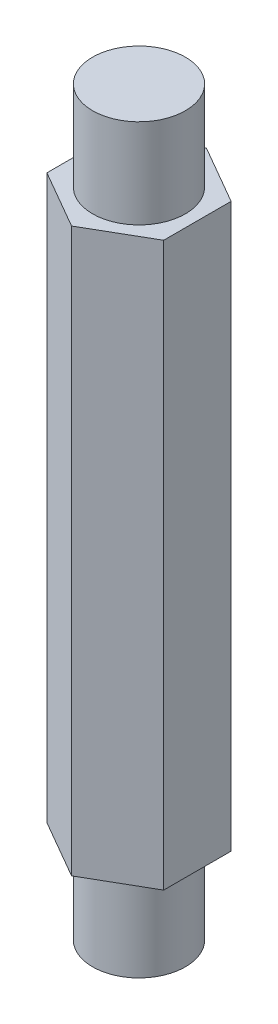
from build123d import *

# Parameters (mm, degrees)
SKETCH1_R           = 1.65
BOSS_EXTRUDE1_DEPTH = 20
SKETCH2_R           = 1.65
BOSS_EXTRUDE2_DEPTH = 3.175
SKETCH3_R           = 1.65
BOSS_EXTRUDE3_DEPTH = 3.175


with BuildPart() as part:
    # Sketch1 → Boss-Extrude1 (new body)
    with BuildSketch(Plane(origin=(0, 0, 0), x_dir=(1, 0, 0), z_dir=(0, 1, 0))):
        Polygon((0, -2.396003617), (2.075, -1.198001809), (2.075, 1.198001809), (0, 2.396003617), (-2.075, 1.198001809), (-2.075, -1.198001809), align=None)
        Circle(SKETCH1_R, mode=Mode.SUBTRACT)
    extrude(amount=BOSS_EXTRUDE1_DEPTH)


with BuildPart() as body_2:
    # Sketch2 → Boss-Extrude2 (new body)
    with BuildSketch(Plane.XZ):
        Circle(SKETCH2_R)
    extrude(amount=BOSS_EXTRUDE2_DEPTH)


with BuildPart() as body_3:
    # Sketch3 → Boss-Extrude3 (new body)
    with BuildSketch(Plane(origin=(0, 20, 0), x_dir=(1, 0, 0), z_dir=(0, 1, 0))):
        Circle(SKETCH3_R)
    extrude(amount=BOSS_EXTRUDE3_DEPTH)


solid = Compound([part.part, body_2.part, body_3.part])
